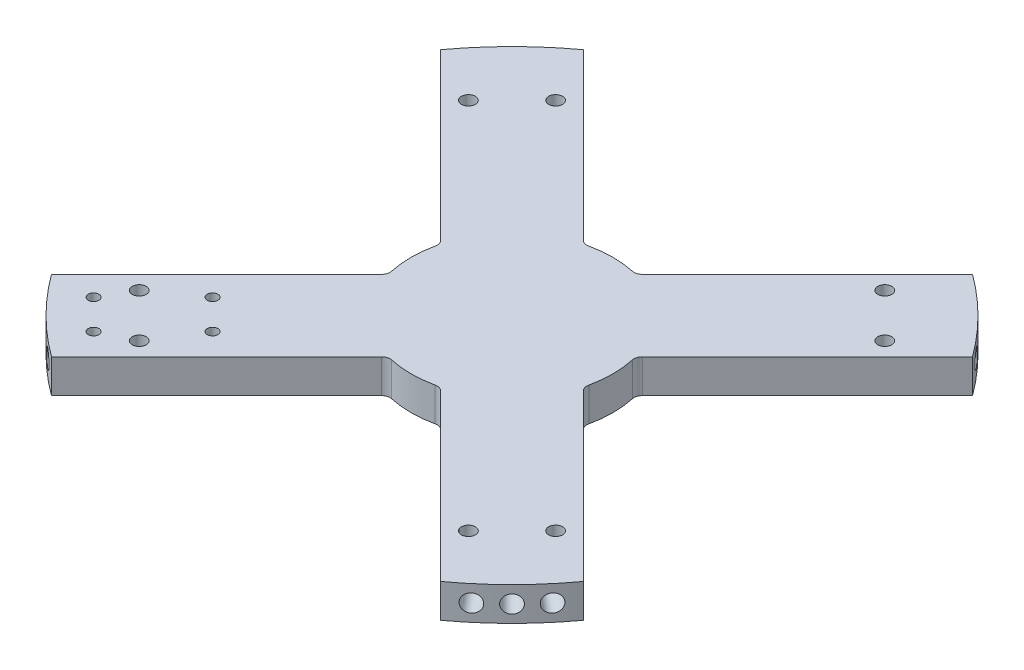
from build123d import *

# Parameters (mm, degrees)
BOSS_EXTRUDE3_DEPTH = 15.24
SKETCH6_R           = 3.175
CUT_EXTRUDE2_DEPTH  = 16.24
CUT_EXTRUDE6_REACH  = 17.24
SKETCH53_R          = 2.413
FILLET1_R           = 3.81
SKETCH57_R          = 3.96875
CUT_EXTRUDE8_DEPTH  = 12.7
SKETCH55_R          = 3.96875
CUT_EXTRUDE9_DEPTH  = 12.7
CIRPATTERN2_COUNT   = 4
SKETCH58_R          = 3.96875
CUT_EXTRUDE10_DEPTH = 12.7
CIRPATTERN3_COUNT   = 4


with BuildPart() as part:
    # Sketch5 → Boss-Extrude3 (new body)
    with BuildSketch(Plane(origin=(0, 0, 0), x_dir=(1, 0, 0), z_dir=(0, 1, 0))):
        with BuildLine():
            Line((-11.833206742, -44.162128778), (-88.108068982, -120.436991017))
            ThreePointArc((-88.108068982, -120.436991017), (-105.518009423, -105.518009423), (-120.436991017, -88.108068982))
            Line((-120.436991017, -88.108068982), (-44.162128778, -11.833206742))
            ThreePointArc((-44.162128778, -11.833206742), (-45.72, 0), (-44.162128778, 11.833206742))
            Line((-44.162128778, 11.833206742), (-120.436991017, 88.108068982))
            ThreePointArc((-120.436991017, 88.108068982), (-105.518009423, 105.518009423), (-88.108068982, 120.436991017))
            Line((-88.108068982, 120.436991017), (-11.833206742, 44.162128778))
            ThreePointArc((-11.833206742, 44.162128778), (0, 45.72), (11.833206742, 44.162128778))
            Line((11.833206742, 44.162128778), (88.108068982, 120.436991017))
            ThreePointArc((88.108068982, 120.436991017), (105.518009423, 105.518009423), (120.436991017, 88.108068982))
            Line((120.436991017, 88.108068982), (44.162128778, 11.833206742))
            ThreePointArc((44.162128778, 11.833206742), (45.72, 0), (44.162128778, -11.833206742))
            Line((44.162128778, -11.833206742), (120.436991017, -88.108068982))
            ThreePointArc((120.436991017, -88.108068982), (105.518009423, -105.518009423), (88.108068982, -120.436991017))
            Line((88.108068982, -120.436991017), (11.833206742, -44.162128778))
            ThreePointArc((11.833206742, -44.162128778), (0, -45.72), (-11.833206742, -44.162128778))
        make_face()
    extrude(amount=BOSS_EXTRUDE3_DEPTH)

    # Sketch6 → Cut-Extrude2 (cut, through all)
    with BuildSketch(Plane(origin=(0, 15.24, 0), x_dir=(1, 0, 0), z_dir=(0, 1, 0))):
        with Locations((-74.536125805, -94.292689271)):
            Circle(SKETCH6_R)
        with Locations((-94.292689271, -74.536125805)):
            Circle(SKETCH6_R)
        with Locations((94.292689271, -74.536125805)):
            Circle(SKETCH6_R)
        with Locations((74.536125805, -94.292689271)):
            Circle(SKETCH6_R)
        with Locations((94.292689271, 74.536125805)):
            Circle(SKETCH6_R)
        with Locations((74.536125805, 94.292689271)):
            Circle(SKETCH6_R)
        with Locations((-94.292689271, 74.536125805)):
            Circle(SKETCH6_R)
        with Locations((-74.536125805, 94.292689271)):
            Circle(SKETCH6_R)
    extrude(amount=-CUT_EXTRUDE2_DEPTH, mode=Mode.SUBTRACT)

    # Sketch53 → Cut-Extrude6 (cut, up to next)
    with BuildSketch(Plane(origin=(0, 15.24, 0), x_dir=(1, 0, 0), z_dir=(0, 1, 0)), mode=Mode.PRIVATE) as cut_extrude6_sk1:
        with Locations((-88.455522793, -101.027881362)):
            Circle(SKETCH53_R)
    cut_extrude6_tool1 = extrude(cut_extrude6_sk1.sketch, amount=-CUT_EXTRUDE6_REACH, mode=Mode.PRIVATE) & part.part
    add(cut_extrude6_tool1.solids().sort_by_distance((-88.455523, 15.24, 101.027881))[0], mode=Mode.SUBTRACT)
    # Sketch53 → Cut-Extrude6 (cut, up to next)
    with BuildSketch(Plane(origin=(0, 15.24, 0), x_dir=(1, 0, 0), z_dir=(0, 1, 0)), mode=Mode.PRIVATE) as cut_extrude6_sk2:
        with Locations((-61.514754429, -74.087112999)):
            Circle(SKETCH53_R)
    cut_extrude6_tool2 = extrude(cut_extrude6_sk2.sketch, amount=-CUT_EXTRUDE6_REACH, mode=Mode.PRIVATE) & part.part
    add(cut_extrude6_tool2.solids().sort_by_distance((-61.514754, 15.24, 74.087113))[0], mode=Mode.SUBTRACT)
    # Sketch53 → Cut-Extrude6 (cut, up to next)
    with BuildSketch(Plane(origin=(0, 15.24, 0), x_dir=(1, 0, 0), z_dir=(0, 1, 0)), mode=Mode.PRIVATE) as cut_extrude6_sk3:
        with Locations((-101.925906974, -87.55749718)):
            Circle(SKETCH53_R)
    cut_extrude6_tool3 = extrude(cut_extrude6_sk3.sketch, amount=-CUT_EXTRUDE6_REACH, mode=Mode.PRIVATE) & part.part
    add(cut_extrude6_tool3.solids().sort_by_distance((-101.925907, 15.24, 87.557497))[0], mode=Mode.SUBTRACT)
    # Sketch53 → Cut-Extrude6 (cut, up to next)
    with BuildSketch(Plane(origin=(0, 15.24, 0), x_dir=(1, 0, 0), z_dir=(0, 1, 0)), mode=Mode.PRIVATE) as cut_extrude6_sk4:
        with Locations((-74.985138611, -60.616728817)):
            Circle(SKETCH53_R)
    cut_extrude6_tool4 = extrude(cut_extrude6_sk4.sketch, amount=-CUT_EXTRUDE6_REACH, mode=Mode.PRIVATE) & part.part
    add(cut_extrude6_tool4.solids().sort_by_distance((-74.985139, 15.24, 60.616729))[0], mode=Mode.SUBTRACT)

    # Fillet1
    fillet1_edges = [part.edges().sort_by_distance(p)[0] for p in [
        (-44.162128778, 7.62, 11.833206742),
        (-44.162128778, 7.62, -11.833206742),
        (-11.833206742, 7.62, -44.162128778),
        (11.833206742, 7.62, -44.162128778),
        (44.162128778, 7.62, -11.833206742),
        (44.162128778, 7.62, 11.833206742),
        (11.833206742, 7.62, 44.162128778),
        (-11.833206742, 7.62, 44.162128778),
    ]]
    fillet(fillet1_edges, radius=FILLET1_R)

    # Sketch57 → Cut-Extrude8 (cut)
    with BuildSketch(Plane(origin=(-114.312982024, 0, 95.919981055), x_dir=(0.64278761, 0, 0.766044443), z_dir=(-0.766044443, 0, 0.64278761))):
        with Locations((0, 7.62)):
            Circle(SKETCH57_R)
    cut_extrude8 = extrude(amount=-CUT_EXTRUDE8_DEPTH, mode=Mode.SUBTRACT)

    # Sketch55 → Cut-Extrude9 (cut)
    with BuildSketch(Plane(origin=(-95.919981055, 0, 114.312982024), x_dir=(0.766044443, 0, 0.64278761), z_dir=(-0.64278761, 0, 0.766044443))):
        with Locations((0, 7.62)):
            Circle(SKETCH55_R)
    cut_extrude9 = extrude(amount=-CUT_EXTRUDE9_DEPTH, mode=Mode.SUBTRACT)

    # CirPattern2: Cut-Extrude8, Cut-Extrude9 ×4 about axis
    cirpattern2_axis = Axis((0, 0, 0), (0, 1, 0))
    for i in range(1, CIRPATTERN2_COUNT):
        add(cut_extrude8.rotate(cirpattern2_axis, i * 360 / CIRPATTERN2_COUNT), mode=Mode.SUBTRACT)
        add(cut_extrude9.rotate(cirpattern2_axis, i * 360 / CIRPATTERN2_COUNT), mode=Mode.SUBTRACT)

    # Sketch58 → Cut-Extrude10 (cut)
    with BuildSketch(Plane(origin=(-105.518009423, 0, 105.518009423), x_dir=(0.707106781, 0, 0.707106781), z_dir=(-0.707106781, 0, 0.707106781))):
        with Locations((0, 7.62)):
            Circle(SKETCH58_R)
    cut_extrude10 = extrude(amount=-CUT_EXTRUDE10_DEPTH, mode=Mode.SUBTRACT)

    # CirPattern3: Cut-Extrude10 ×4 about axis
    cirpattern3_axis = Axis((0, 0, 0), (0, 1, 0))
    for i in range(1, CIRPATTERN3_COUNT):
        add(cut_extrude10.rotate(cirpattern3_axis, i * 360 / CIRPATTERN3_COUNT), mode=Mode.SUBTRACT)


solid = part.part
